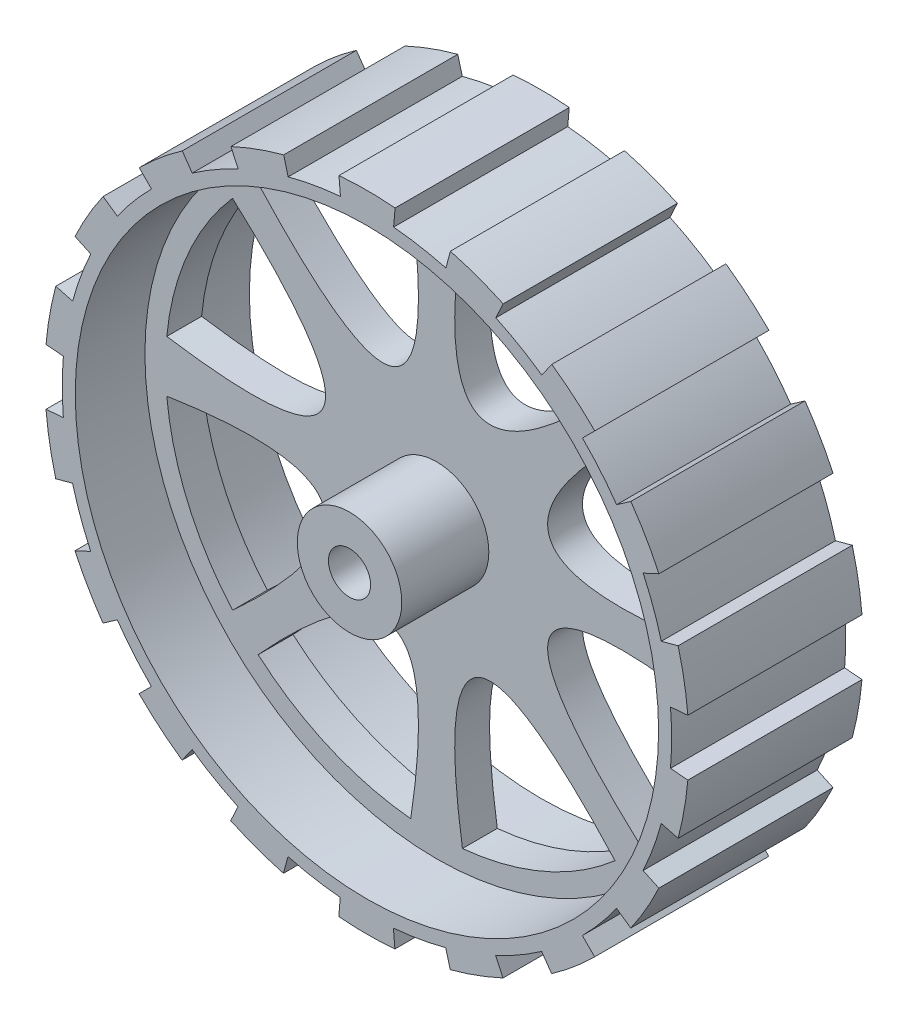
from build123d import *

# Parameters (mm, degrees)
BOSS_EXTRUDE1_DEPTH      = 2
BOSS_EXTRUDE1_DEPTH_BACK = 2
SKETCH1_R                = 33.5
BOSS_EXTRUDE2_DEPTH      = 10
BOSS_EXTRUDE2_DEPTH_BACK = 10
SKETCH1_3_R              = 33.5
BOSS_EXTRUDE3_DEPTH      = 12
BOSS_EXTRUDE3_DEPTH_BACK = 4
SKETCH1_4_R              = 6
CUT_EXTRUDE1_DEPTH       = 12
CUT_EXTRUDE1_DEPTH_BACK  = 4
SKETCH1_8_R              = 2.421700836


with BuildPart() as part:
    # Sketch1 → Boss-Extrude1 (new, two sides: drawn at the far end of the back side and taken through both)
    with BuildSketch(Plane.XY.offset(-BOSS_EXTRUDE1_DEPTH_BACK)):
        Circle(SKETCH1_R)
        with BuildLine():
            ThreePointArc((2.969330018, 30.988493446), (12.323014144, 28.587531709), (20.490865046, 23.435615982))
            add(Edge.make_bspline(
                [(2.969330018, 30.988493446), (-1.959681003, -1.194375065), (20.490865046, 23.435615982)],
                knots=[0, 0, 0, 1, 1, 1], degree=2))
        make_face(mode=Mode.SUBTRACT)
        with BuildLine():
            ThreePointArc((30.988493446, 2.969330018), (28.587531709, 12.323014144), (23.435615982, 20.490865046))
            add(Edge.make_bspline(
                [(30.988493446, 2.969330018), (-1.194375065, -1.959681003), (23.435615982, 20.490865046)],
                knots=[0, 0, 0, 1, 1, 1], degree=2))
        make_face(mode=Mode.SUBTRACT)
        with BuildLine():
            ThreePointArc((30.988493446, -2.969330018), (28.587531709, -12.323014144), (23.435615982, -20.490865046))
            add(Edge.make_bspline(
                [(30.988493446, -2.969330018), (-1.194375065, 1.959681003), (23.435615982, -20.490865046)],
                knots=[0, 0, 0, 1, 1, 1], degree=2))
        make_face(mode=Mode.SUBTRACT)
        with BuildLine():
            ThreePointArc((2.969330018, -30.988493446), (12.323014144, -28.587531709), (20.490865046, -23.435615982))
            add(Edge.make_bspline(
                [(2.969330018, -30.988493446), (-1.959681003, 1.194375065), (20.490865046, -23.435615982)],
                knots=[0, 0, 0, 1, 1, 1], degree=2))
        make_face(mode=Mode.SUBTRACT)
        with BuildLine():
            ThreePointArc((-2.969330018, -30.988493446), (-12.323014144, -28.587531709), (-20.490865046, -23.435615982))
            add(Edge.make_bspline(
                [(-2.969330018, -30.988493446), (1.959681003, 1.194375065), (-20.490865046, -23.435615982)],
                knots=[0, 0, 0, 1, 1, 1], degree=2))
        make_face(mode=Mode.SUBTRACT)
        with BuildLine():
            ThreePointArc((-30.988493446, -2.969330018), (-28.587531709, -12.323014144), (-23.435615982, -20.490865046))
            add(Edge.make_bspline(
                [(-30.988493446, -2.969330018), (1.194375065, 1.959681003), (-23.435615982, -20.490865046)],
                knots=[0, 0, 0, 1, 1, 1], degree=2))
        make_face(mode=Mode.SUBTRACT)
        with BuildLine():
            ThreePointArc((-30.988493446, 2.969330018), (-28.587531709, 12.323014144), (-23.435615982, 20.490865046))
            add(Edge.make_bspline(
                [(-30.988493446, 2.969330018), (1.194375065, -1.959681003), (-23.435615982, 20.490865046)],
                knots=[0, 0, 0, 1, 1, 1], degree=2))
        make_face(mode=Mode.SUBTRACT)
        with BuildLine():
            ThreePointArc((-2.969330018, 30.988493446), (-12.323014144, 28.587531709), (-20.490865046, 23.435615982))
            add(Edge.make_bspline(
                [(-2.969330018, 30.988493446), (1.959681003, -1.194375065), (-20.490865046, 23.435615982)],
                knots=[0, 0, 0, 1, 1, 1], degree=2))
        make_face(mode=Mode.SUBTRACT)
    extrude(amount=BOSS_EXTRUDE1_DEPTH + BOSS_EXTRUDE1_DEPTH_BACK)


with BuildPart() as body_2:
    # Sketch1_3 → Boss-Extrude2 (new, two sides: drawn at the far end of the back side and taken through both)
    with BuildSketch(Plane.XY.offset(-BOSS_EXTRUDE2_DEPTH_BACK)):
        with BuildLine():
            Line((3.236863537, 36.858143123), (3.06189794, 34.865811062))
            ThreePointArc((3.06189794, 34.865811062), (6.088998939, 34.466274703), (9.069759079, 33.804429743))
            Line((9.069759079, 33.804429743), (9.588031026, 35.736111443))
            ThreePointArc((9.588031026, 35.736111443), (12.666156251, 34.764471603), (15.647884173, 33.528252577))
            Line((15.647884173, 33.528252577), (14.802052596, 31.7159146))
            ThreePointArc((14.802052596, 31.7159146), (17.509947585, 30.305143715), (20.084581584, 28.66373288))
            Line((20.084581584, 28.66373288), (21.23227196, 30.301660473))
            ThreePointArc((21.23227196, 30.301660473), (23.792443123, 28.335836854), (26.171539041, 26.154359947))
            Line((26.171539041, 26.154359947), (24.756861255, 24.740610761))
            ThreePointArc((24.756861255, 24.740610761), (26.818938133, 22.488765138), (28.676907134, 20.065766799))
            Line((28.676907134, 20.065766799), (30.315587542, 21.212382045))
            ThreePointArc((30.315587542, 21.212382045), (32.049010215, 18.489481989), (33.538520049, 15.62586551))
            Line((33.538520049, 15.62586551), (31.725627073, 14.781224131))
            ThreePointArc((31.725627073, 14.781224131), (32.893168936, 11.959909587), (33.810374457, 9.047573103))
            Line((33.810374457, 9.047573103), (35.742395855, 9.564577281))
            ThreePointArc((35.742395855, 9.564577281), (36.439993683, 6.41302272), (36.860260563, 3.212661079))
            Line((36.860260563, 3.212661079), (34.867814046, 3.039003724))
            ThreePointArc((34.867814046, 3.039003724), (34.999998115, -0.01148757), (34.865811633, -3.061891437))
            Line((34.865811633, -3.061891437), (36.858143726, -3.236856661))
            ThreePointArc((36.858143726, -3.236856661), (36.435776115, -6.436941736), (35.736109654, -9.588037692))
            Line((35.736109654, -9.588037692), (33.804428051, -9.069765384))
            ThreePointArc((33.804428051, -9.069765384), (32.885310976, -11.981499156), (31.715917361, -14.80204668))
            Line((31.715917361, -14.80204668), (33.528255496, -15.647877919))
            ThreePointArc((33.528255496, -15.647877919), (32.036866213, -18.510516018), (30.301656512, -21.232277613))
            Line((30.301656512, -21.232277613), (28.663729133, -20.084586931))
            ThreePointArc((28.663729133, -20.084586931), (26.804169997, -22.506365116), (24.740615379, -24.75685664))
            Line((24.740615379, -24.75685664), (26.154364829, -26.171534162))
            ThreePointArc((26.154364829, -26.171534162), (23.773837432, -28.351448883), (21.21237639, -30.315591498))
            Line((21.21237639, -30.315591498), (20.06576145, -28.676910877))
            ThreePointArc((20.06576145, -28.676910877), (17.49005053, -30.316631285), (14.781230049, -31.725624316))
            Line((14.781230049, -31.725624316), (15.625871766, -33.538517134))
            ThreePointArc((15.625871766, -33.538517134), (12.643332992, -34.77277859), (9.564570614, -35.742397639))
            Line((9.564570614, -35.742397639), (9.047566797, -33.810376145))
            ThreePointArc((9.047566797, -33.810376145), (6.066372843, -34.470264294), (3.039010227, -34.867813479))
            Line((3.039010227, -34.867813479), (3.212667955, -36.860259964))
            ThreePointArc((3.212667955, -36.860259964), (-0.012144003, -36.999998007), (-3.236863537, -36.858143123))
            Line((-3.236863537, -36.858143123), (-3.06189794, -34.865811062))
            ThreePointArc((-3.06189794, -34.865811062), (-6.088998939, -34.466274703), (-9.069759079, -33.804429743))
            Line((-9.069759079, -33.804429743), (-9.588031026, -35.736111443))
            ThreePointArc((-9.588031026, -35.736111443), (-12.666156251, -34.764471603), (-15.647884173, -33.528252577))
            Line((-15.647884173, -33.528252577), (-14.802052596, -31.7159146))
            ThreePointArc((-14.802052596, -31.7159146), (-17.509947585, -30.305143715), (-20.084581584, -28.66373288))
            Line((-20.084581584, -28.66373288), (-21.23227196, -30.301660473))
            ThreePointArc((-21.23227196, -30.301660473), (-23.792443123, -28.335836854), (-26.171539041, -26.154359947))
            Line((-26.171539041, -26.154359947), (-24.756861255, -24.740610761))
            ThreePointArc((-24.756861255, -24.740610761), (-26.818938133, -22.488765138), (-28.676907134, -20.065766799))
            Line((-28.676907134, -20.065766799), (-30.315587542, -21.212382045))
            ThreePointArc((-30.315587542, -21.212382045), (-32.049010215, -18.489481989), (-33.538520049, -15.62586551))
            Line((-33.538520049, -15.62586551), (-31.725627073, -14.781224131))
            ThreePointArc((-31.725627073, -14.781224131), (-32.893168936, -11.959909587), (-33.810374457, -9.047573103))
            Line((-33.810374457, -9.047573103), (-35.742395855, -9.564577281))
            ThreePointArc((-35.742395855, -9.564577281), (-36.439993683, -6.41302272), (-36.860260563, -3.212661079))
            Line((-36.860260563, -3.212661079), (-34.867814046, -3.039003724))
            ThreePointArc((-34.867814046, -3.039003724), (-34.999998115, 0.01148757), (-34.865811633, 3.061891437))
            Line((-34.865811633, 3.061891437), (-36.858143726, 3.236856661))
            ThreePointArc((-36.858143726, 3.236856661), (-36.435776115, 6.436941736), (-35.736109654, 9.588037692))
            Line((-35.736109654, 9.588037692), (-33.804428051, 9.069765384))
            ThreePointArc((-33.804428051, 9.069765384), (-32.885310976, 11.981499156), (-31.715917361, 14.80204668))
            Line((-31.715917361, 14.80204668), (-33.528255496, 15.647877919))
            ThreePointArc((-33.528255496, 15.647877919), (-32.036866213, 18.510516018), (-30.301656512, 21.232277613))
            Line((-30.301656512, 21.232277613), (-28.663729133, 20.084586931))
            ThreePointArc((-28.663729133, 20.084586931), (-26.804169997, 22.506365116), (-24.740615379, 24.75685664))
            Line((-24.740615379, 24.75685664), (-26.154364829, 26.171534162))
            ThreePointArc((-26.154364829, 26.171534162), (-23.773837432, 28.351448883), (-21.21237639, 30.315591498))
            Line((-21.21237639, 30.315591498), (-20.06576145, 28.676910877))
            ThreePointArc((-20.06576145, 28.676910877), (-17.49005053, 30.316631285), (-14.781230049, 31.725624316))
            Line((-14.781230049, 31.725624316), (-15.625871766, 33.538517134))
            ThreePointArc((-15.625871766, 33.538517134), (-12.643332992, 34.77277859), (-9.564570614, 35.742397639))
            Line((-9.564570614, 35.742397639), (-9.047566797, 33.810376145))
            ThreePointArc((-9.047566797, 33.810376145), (-6.066372843, 34.470264294), (-3.039010227, 34.867813479))
            Line((-3.039010227, 34.867813479), (-3.212667955, 36.860259964))
            ThreePointArc((-3.212667955, 36.860259964), (0.012144003, 36.999998007), (3.236863537, 36.858143123))
        make_face()
        Circle(SKETCH1_3_R, mode=Mode.SUBTRACT)
    extrude(amount=BOSS_EXTRUDE2_DEPTH + BOSS_EXTRUDE2_DEPTH_BACK)


with BuildPart() as body_3:
    # Sketch1_4 → Boss-Extrude3 (new, two sides: drawn at the far end of the back side and taken through both)
    with BuildSketch(Plane.XY.offset(-BOSS_EXTRUDE3_DEPTH_BACK)):
        Circle(SKETCH1_4_R)
    extrude(amount=BOSS_EXTRUDE3_DEPTH + BOSS_EXTRUDE3_DEPTH_BACK)


with BuildPart() as cut_extrude1_tool:
    # Sketch1_8 → Cut-Extrude1 (new, two sides: drawn at the far end of the back side and taken through both)
    with BuildSketch(Plane.XY.offset(-CUT_EXTRUDE1_DEPTH_BACK)):
        with Locations((0, -0.051384877)):
            Circle(SKETCH1_8_R)
    extrude(amount=CUT_EXTRUDE1_DEPTH + CUT_EXTRUDE1_DEPTH_BACK)


with BuildPart() as part_1:
    add(part.part)

    # Cut-Extrude1: cut by cut_extrude1_tool
    add(cut_extrude1_tool.part, mode=Mode.SUBTRACT)


with BuildPart() as body_3_1:
    add(body_3.part)

    # Cut-Extrude1: cut by cut_extrude1_tool
    add(cut_extrude1_tool.part, mode=Mode.SUBTRACT)


solid = Compound([body_2.part, part_1.part, body_3_1.part])
